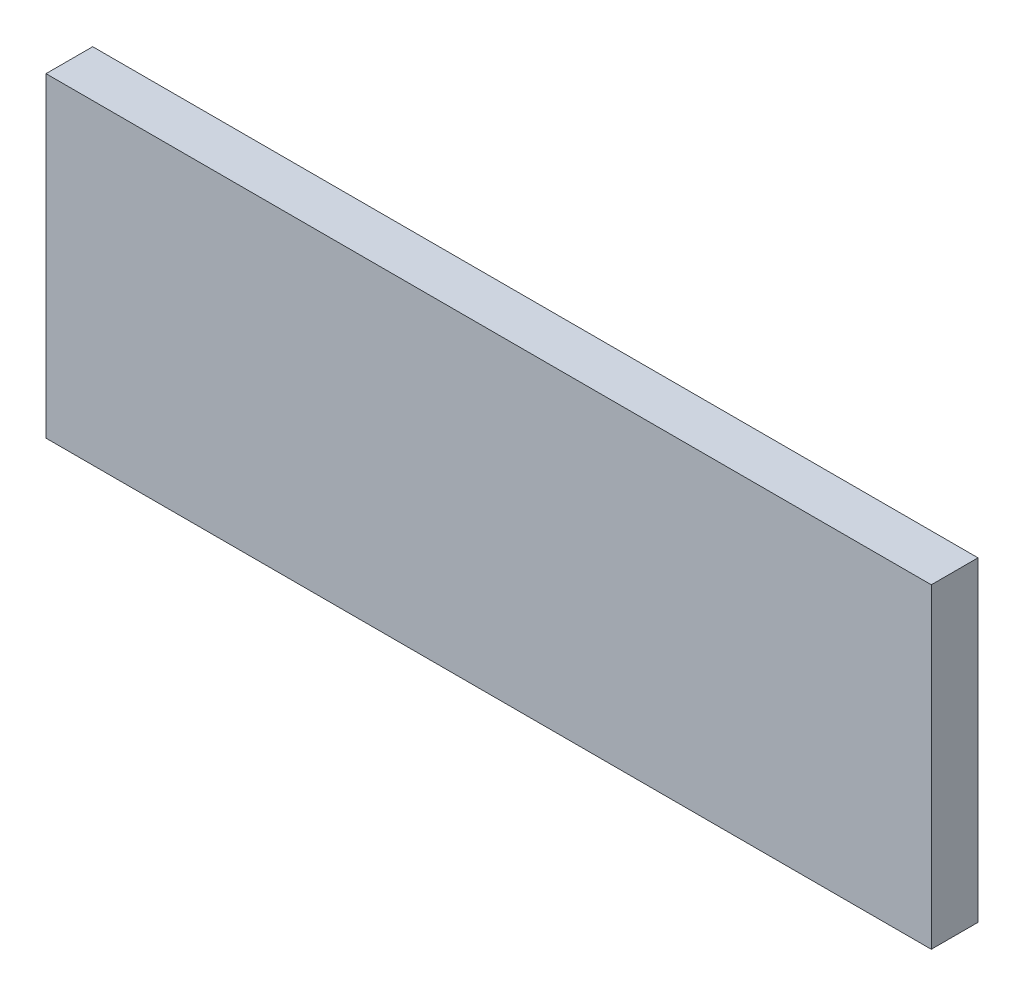
from build123d import *

# Parameters (mm, degrees)
ESQUISSE1_W        = 284.342394654
ESQUISSE1_H        = 101.399999226
BOSS_EXTRU_1_DEPTH = 15


with BuildPart() as part:
    # Esquisse1 → Boss.-Extru.1 (new body)
    with BuildSketch(Plane.XY):
        Rectangle(ESQUISSE1_W, ESQUISSE1_H)
    extrude(amount=BOSS_EXTRU_1_DEPTH)


solid = part.part
